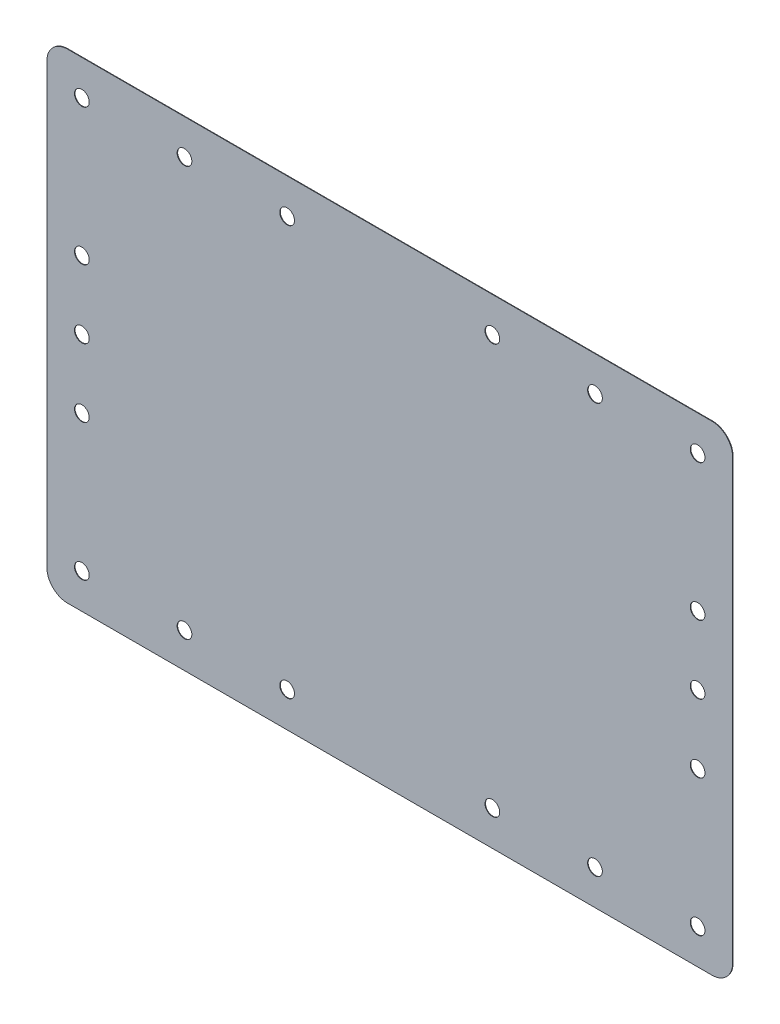
from build123d import *

# Parameters (mm, degrees)
MODEL_R             = 1.775
BOSS_EXTRUDE1_DEPTH = 0.127


with BuildPart() as part:
    # Model → Boss-Extrude1 (new body)
    with BuildSketch(Plane.XY):
        with BuildLine():
            Line((82.807124219, -52.938976545), (82.807124219, 52.938976545))
            ThreePointArc((82.807124219, 52.938976545), (81.344473074, 56.469473074), (77.813976545, 57.932124219))
            Line((77.813976545, 57.932124219), (-77.813976545, 57.932124219))
            ThreePointArc((-77.813976545, 57.932124219), (-81.344473074, 56.469473074), (-82.807124219, 52.938976545))
            Line((-82.807124219, 52.938976545), (-82.807124219, -52.938976545))
            ThreePointArc((-82.807124219, -52.938976545), (-81.344473074, -56.469473074), (-77.813976545, -57.932124219))
            Line((-77.813976545, -57.932124219), (77.813976545, -57.932124219))
            ThreePointArc((77.813976545, -57.932124219), (81.344473074, -56.469473074), (82.807124219, -52.938976545))
        make_face()
        with Locations((-74.348042359, 49.473042359)):
            Circle(MODEL_R, mode=Mode.SUBTRACT)
        with Locations((-24.782680786, 49.473042359)):
            Circle(MODEL_R, mode=Mode.SUBTRACT)
        with Locations((24.782680786, 49.473042359)):
            Circle(MODEL_R, mode=Mode.SUBTRACT)
        with Locations((74.348042359, 49.473042359)):
            Circle(MODEL_R, mode=Mode.SUBTRACT)
        with Locations((74.348042359, 16.49101412)):
            Circle(MODEL_R, mode=Mode.SUBTRACT)
        with Locations((74.348042359, -16.49101412)):
            Circle(MODEL_R, mode=Mode.SUBTRACT)
        with Locations((74.348042359, -49.473042359)):
            Circle(MODEL_R, mode=Mode.SUBTRACT)
        with Locations((24.782680786, -49.473042359)):
            Circle(MODEL_R, mode=Mode.SUBTRACT)
        with Locations((-24.782680786, -49.473042359)):
            Circle(MODEL_R, mode=Mode.SUBTRACT)
        with Locations((-74.348042359, -49.473042359)):
            Circle(MODEL_R, mode=Mode.SUBTRACT)
        with Locations((-74.348042359, -16.49101412)):
            Circle(MODEL_R, mode=Mode.SUBTRACT)
        with Locations((-74.348042359, 16.49101412)):
            Circle(MODEL_R, mode=Mode.SUBTRACT)
        with Locations((49.565361573, -49.473042359)):
            Circle(MODEL_R, mode=Mode.SUBTRACT)
        with Locations((-49.565361573, -49.473042359)):
            Circle(MODEL_R, mode=Mode.SUBTRACT)
        with Locations((-49.565361573, 49.473042359)):
            Circle(MODEL_R, mode=Mode.SUBTRACT)
        with Locations((49.565361573, 49.473042359)):
            Circle(MODEL_R, mode=Mode.SUBTRACT)
        with Locations((-74.348042359, 0)):
            Circle(MODEL_R, mode=Mode.SUBTRACT)
        with Locations((74.348042359, 0)):
            Circle(MODEL_R, mode=Mode.SUBTRACT)
    extrude(amount=BOSS_EXTRUDE1_DEPTH)


solid = part.part
